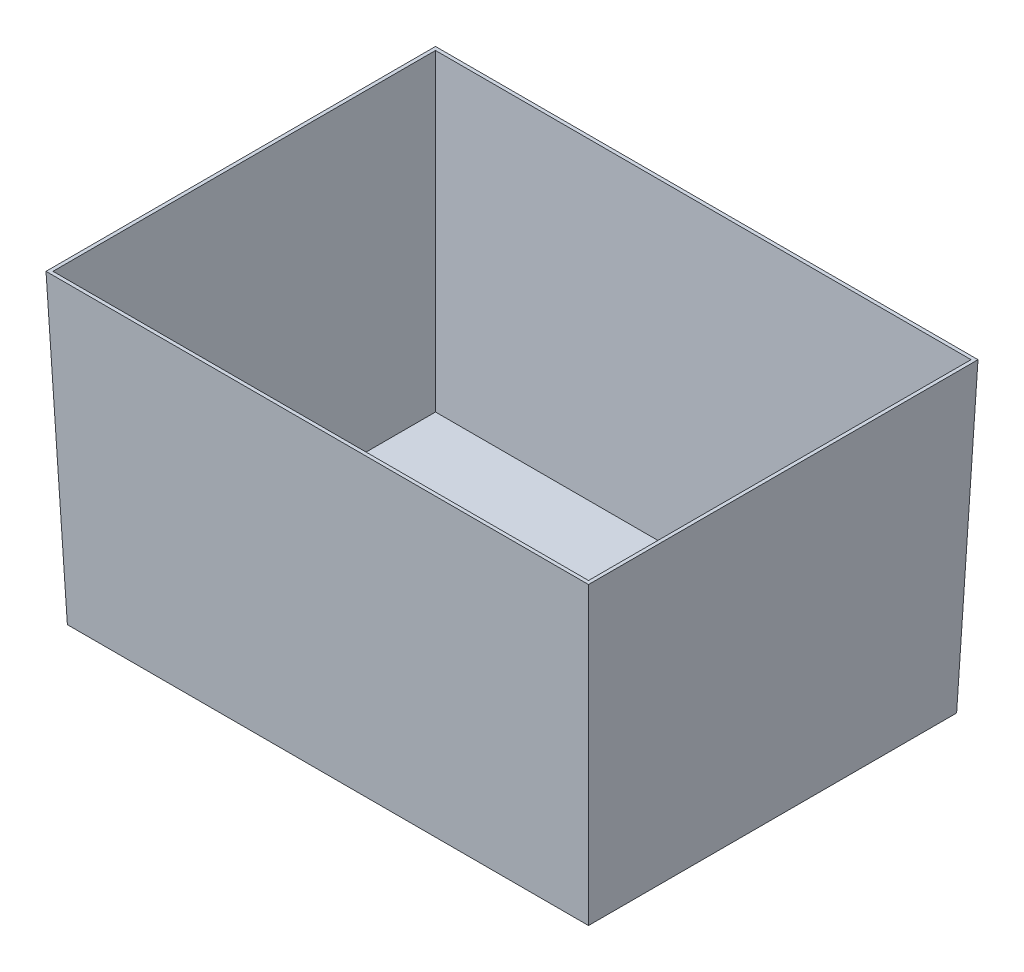
from build123d import *

# Parameters (mm, degrees)
SKETCH1_W      = 780
SKETCH1_H      = 560
EXTRUDE1_DEPTH = 440
EXTRUDE1_TAPER = 2
SHELL1_T       = -5


with BuildPart() as part:
    # Sketch1 → Extrude1 (new body)
    with BuildSketch(Plane(origin=(0, 0, 0), x_dir=(1, 0, 0), z_dir=(0, 1, 0))):
        Rectangle(SKETCH1_W, SKETCH1_H)
    extrude(amount=-EXTRUDE1_DEPTH, taper=EXTRUDE1_TAPER)

    # Shell1
    shell1_openings = [part.faces().sort_by_distance(p)[0] for p in [
        (0, 0, 0),
    ]]
    offset(amount=SHELL1_T, openings=shell1_openings, kind=Kind.INTERSECTION)


solid = part.part
